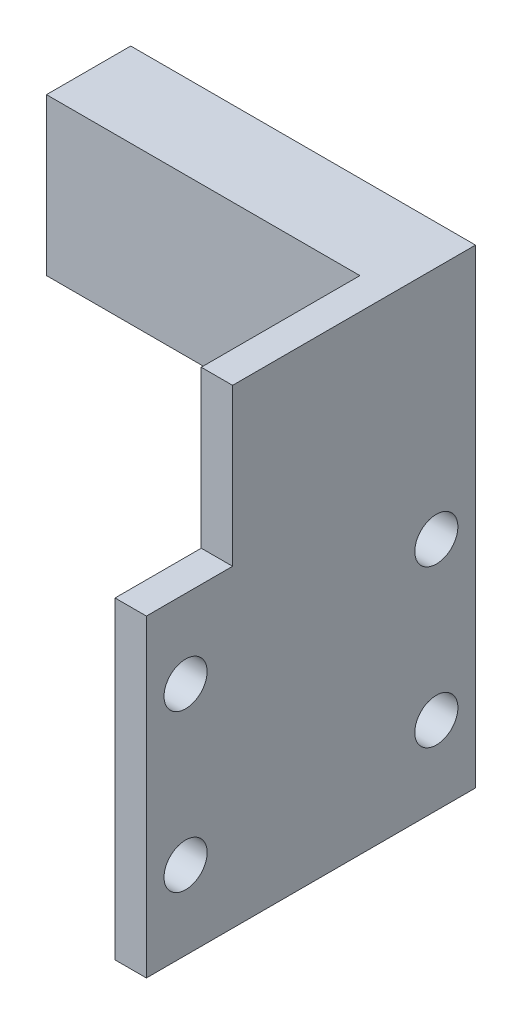
from build123d import *

# Parameters (mm, degrees)
SKETCH1_W           = 42
SKETCH1_H           = 40
SKETCH1_R           = 2.75
BOSS_EXTRUDE1_DEPTH = 4
BOSS_EXTRUDE2_DEPTH = 20


with BuildPart() as part:
    # Sketch1 → Boss-Extrude1 (new body)
    with BuildSketch(Plane(origin=(0, 0, 0), x_dir=(0, 0, -1), z_dir=(1, 0, 0))):
        with Locations((21, 20)):
            Rectangle(SKETCH1_W, SKETCH1_H)
        with Locations((5, 30)):
            Circle(SKETCH1_R, mode=Mode.SUBTRACT)
        with Locations((5, 10)):
            Circle(SKETCH1_R, mode=Mode.SUBTRACT)
        with Locations((37, 10)):
            Circle(SKETCH1_R, mode=Mode.SUBTRACT)
        with Locations((37, 30)):
            Circle(SKETCH1_R, mode=Mode.SUBTRACT)
    extrude(amount=-BOSS_EXTRUDE1_DEPTH)

    # Sketch3 → Boss-Extrude2 (add)
    with BuildSketch(Plane(origin=(0, 40, 0), x_dir=(1, 0, 0), z_dir=(0, 1, 0))):
        Polygon((0, 42), (-44, 42), (-44, 31.25), (-4, 31.25), (-4, 11), (0, 11), align=None)
    extrude(amount=BOSS_EXTRUDE2_DEPTH)


solid = part.part
